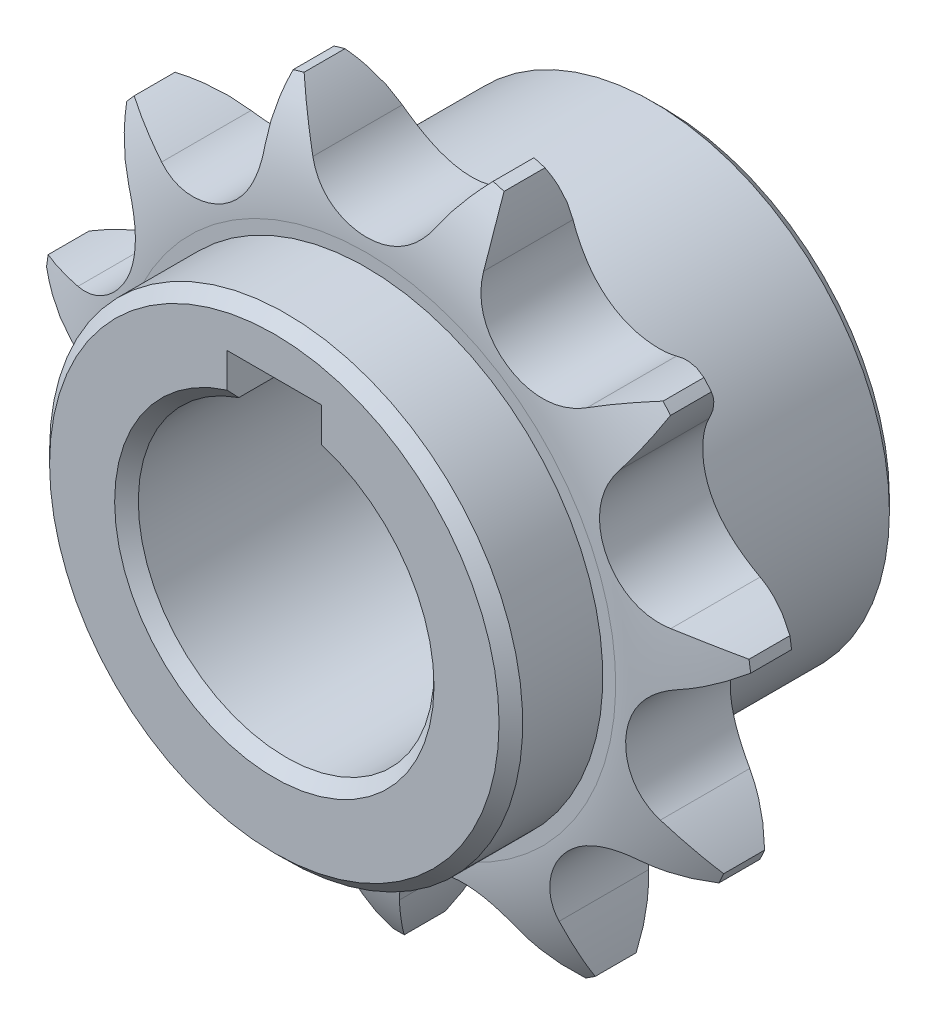
from build123d import *

# Parameters (mm, degrees)
EXTRUDE_1_DEPTH          = 8.93
PATTERN_CIRCULAR_1_COUNT = 11
SKETCH_3_R               = 20
EXTRUDE_2_DEPTH          = 7.77
SKETCH_4_R               = 20
EXTRUDE_3_DEPTH          = 16.3
CUT_EXTRUDE_1_REACH      = 55.616
SKETCH_5_R               = 12.5
CHAMFER_1_SIZE           = 1
CUT_EXTRUDE_2_REACH      = 55.616
HOLE_WIZARD_M5_1_REACH   = 68.581
HOLE_WIZARD_M5_1_BORE_R  = 2.1


with BuildPart() as part:
    # 草图1 → 凸台-拉伸1 (new body)
    with BuildSketch(Plane.XY):
        with BuildLine():
            Line((0, 22.1739), (0, 0))
            Line((0, 0), (11.988115422, 18.653871712))
            ThreePointArc((11.988115422, 18.653871712), (9.898947635, 20.952033778), (9.238756292, 23.986884404))
            ThreePointArc((9.238756292, 23.986884404), (9.213272367, 26.325306218), (8.91500328, 28.644767699))
            ThreePointArc((8.91500328, 28.644767699), (8.451976705, 28.784789208), (7.98675262, 28.917326685))
            ThreePointArc((7.98675262, 28.917326685), (6.481837146, 27.127327962), (5.196152423, 25.1739))
            ThreePointArc((5.196152423, 25.1739), (3, 22.977747577), (0, 22.1739))
        make_face()
    extrude_1 = extrude(amount=EXTRUDE_1_DEPTH)

    # 阵列(圆周)1: 凸台-拉伸1 ×11 about axis
    pattern_circular_1_axis = Axis((0, 0, 0), (0, 0, 1))
    for i in range(1, PATTERN_CIRCULAR_1_COUNT):
        add(extrude_1.rotate(pattern_circular_1_axis, i * 360 / PATTERN_CIRCULAR_1_COUNT))

    # 草图2 → 切除-旋转1 (revolve, cut)
    with BuildSketch(Plane(origin=(0, 0, 0), x_dir=(0, 0, -1), z_dir=(1, 0, 0))):
        with BuildLine():
            Line((-8.93, 21.090130607), (-8.93, 33.564786397))
            Line((-8.93, 33.564786397), (0, 33.564786397))
            Line((0, 33.564786397), (0, 21.090130607))
            ThreePointArc((0, 21.090130607), (-1.158523265, 27.043359773), (-4.465, 32.127681286))
            ThreePointArc((-4.465, 32.127681286), (-7.771476735, 27.043359773), (-8.93, 21.090130607))
        make_face()
    revolve(axis=Axis((0, 0, 0), (0, 0, 1)), mode=Mode.SUBTRACT)

    # 草图3 → 凸台-拉伸2 (add)
    with BuildSketch(Plane.XY.offset(8.93)):
        with Locations(Location((0, 0, 0), (0, 0, 180))):
            Circle(SKETCH_3_R)
    extrude(amount=EXTRUDE_2_DEPTH)

    # 草图4 → 凸台-拉伸3 (add)
    with BuildSketch(Plane(origin=(0, 0, 0), x_dir=(-1, 0, 0), z_dir=(0, 0, -1))):
        Circle(SKETCH_4_R)
    extrude(amount=EXTRUDE_3_DEPTH)

    # 草图5 → 切除-拉伸1 (cut, up to next)
    with BuildSketch(Plane.XY.offset(16.7), mode=Mode.PRIVATE) as cut_extrude_1_sk1:
        Circle(SKETCH_5_R)
    cut_extrude_1_tool1 = extrude(cut_extrude_1_sk1.sketch, amount=-CUT_EXTRUDE_1_REACH, mode=Mode.PRIVATE) & part.part
    add(cut_extrude_1_tool1.solids().sort_by_distance((0, 0, 16.7))[0], mode=Mode.SUBTRACT)

    # 倒角1
    chamfer_1_edges = [part.edges().sort_by_distance(p)[0] for p in [
        (20, 0, 16.7),
        (20, 0, -16.3),
        (-12.5, 0, -16.3),
        (-12.5, 0, 16.7),
    ]]
    chamfer(chamfer_1_edges, length=CHAMFER_1_SIZE)

    # 草图6 → 切除-拉伸2 (cut, up to next)
    with BuildSketch(Plane.XY.offset(16.7), mode=Mode.PRIVATE) as cut_extrude_2_sk1:
        with BuildLine():
            Line((4, 11.842719282), (4, 15.8))
            Line((4, 15.8), (-4, 15.8))
            Line((-4, 15.8), (-4, 11.842719282))
            ThreePointArc((-4, 11.842719282), (0, 12.5), (4, 11.842719282))
        make_face()
    cut_extrude_2_tool1 = extrude(cut_extrude_2_sk1.sketch, amount=-CUT_EXTRUDE_2_REACH, mode=Mode.PRIVATE) & part.part
    add(cut_extrude_2_tool1.solids().sort_by_distance((0, 14.036215, 16.7))[0], mode=Mode.SUBTRACT)

    # M5 螺纹孔1 bore (on position points) → M5 螺纹孔1 (cut, up to next)
    with BuildSketch(Plane(origin=(-15.746043967, 12.331346211, -7.180250133), x_dir=(-0.616567310564, -0.787302198361, 0), z_dir=(-0.787302198361, 0.616567310564, 0)), mode=Mode.PRIVATE) as hole_wizard_m5_1_sk1:
        Circle(HOLE_WIZARD_M5_1_BORE_R)
    hole_wizard_m5_1_tool1 = extrude(hole_wizard_m5_1_sk1.sketch, amount=-HOLE_WIZARD_M5_1_REACH, mode=Mode.PRIVATE) & part.part
    add(hole_wizard_m5_1_tool1.solids().sort_by_distance((-15.746044, 12.331346, -7.18025))[0], mode=Mode.SUBTRACT)


solid = part.part
